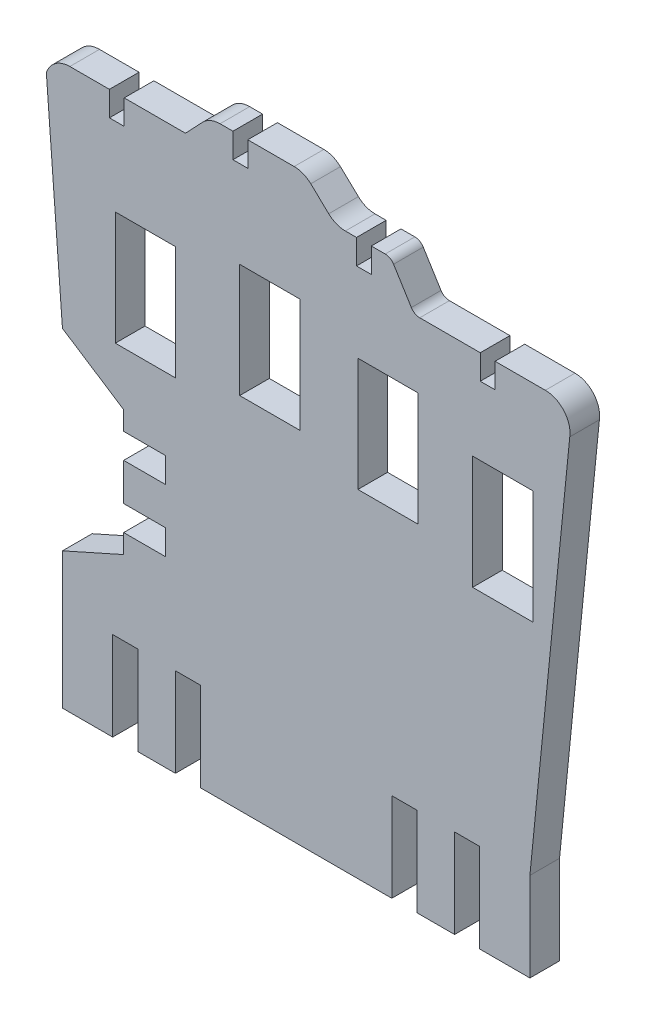
from build123d import *

# Parameters (mm, degrees)
SKETCH1_W           = 12.2
SKETCH1_H           = 23
BOSS_EXTRUDE1_DEPTH = 6


with BuildPart() as part:
    # Sketch1 → Boss-Extrude1 (new body)
    with BuildSketch(Plane.XY):
        with BuildLine():
            Line((21.077436259, 96.487236066), (24.514288944, 100.118770675))
            ThreePointArc((24.514288944, 100.118770675), (26.133905044, 101.250028723), (28.068821983, 101.648773655))
            Line((28.068821983, 101.648773655), (30.683177697, 101.648773655))
            Line((30.683177697, 101.648773655), (30.683177697, 96.648773655))
            Line((30.683177697, 96.648773655), (33.683177697, 96.648773655))
            Line((33.683177697, 96.648773655), (33.683177697, 101.648773655))
            Line((33.683177697, 101.648773655), (43.068821983, 101.648773655))
            ThreePointArc((43.068821983, 101.648773655), (44.879241743, 101.301597143), (46.432801053, 100.309324643))
            Line((46.432801053, 100.309324643), (50.064335662, 96.872471958))
            ThreePointArc((50.064335662, 96.872471958), (51.617894972, 95.880199458), (53.428314733, 95.533022946))
            Line((53.428314733, 95.533022946), (55.683177697, 95.533022946))
            Line((55.683177697, 95.533022946), (55.683177697, 90.533022946))
            Line((55.683177697, 90.533022946), (58.683177697, 90.533022946))
            Line((58.683177697, 90.533022946), (58.683177697, 95.533022946))
            Line((58.683177697, 95.533022946), (61.489325132, 95.533022946))
            ThreePointArc((61.489325132, 95.533022946), (62.461477954, 95.280855573), (63.188485552, 94.587941837))
            Line((63.188485552, 94.587941837), (66.784051646, 88.796554795))
            ThreePointArc((66.784051646, 88.796554795), (67.511059245, 88.10364106), (68.483212066, 87.851473686))
            Line((68.483212066, 87.851473686), (80.727367549, 87.851473686))
            Line((80.727367549, 87.851473686), (80.727367549, 82.851473686))
            Line((80.727367549, 82.851473686), (83.727367549, 82.851473686))
            Line((83.727367549, 82.851473686), (83.727367549, 87.851473686))
            Line((83.727367549, 87.851473686), (93.887367549, 87.851473686))
            ThreePointArc((93.887367549, 87.851473686), (97.660193959, 86.132598628), (98.839013483, 82.157786039))
            Line((98.839013483, 82.157786039), (90.771737035, 1.27912723))
            Line((90.771737035, 1.27912723), (90.771737035, -16.699114739))
            Line((90.771737035, -16.699114739), (80.611737035, -16.699114739))
            Line((80.611737035, -16.699114739), (80.611737035, 1.27912723))
            Line((80.611737035, 1.27912723), (75.531737035, 1.27912723))
            Line((75.531737035, 1.27912723), (75.531737035, -16.699114739))
            Line((75.531737035, -16.699114739), (67.911737035, -16.699114739))
            Line((67.911737035, -16.699114739), (67.911737035, 1.27912723))
            Line((67.911737035, 1.27912723), (62.831737035, 1.27912723))
            Line((62.831737035, 1.27912723), (62.831737035, -16.699114739))
            Line((62.831737035, -16.699114739), (24.124020717, -16.699114739))
            Line((24.124020717, -16.699114739), (24.124020717, 1.27912723))
            Line((24.124020717, 1.27912723), (19.044020717, 1.27912723))
            Line((19.044020717, 1.27912723), (19.044020717, -16.699114739))
            Line((19.044020717, -16.699114739), (11.424020717, -16.699114739))
            Line((11.424020717, -16.699114739), (11.424020717, 1.27912723))
            Line((11.424020717, 1.27912723), (6.344020717, 1.27912723))
            Line((6.344020717, 1.27912723), (6.344020717, -16.699114739))
            Line((6.344020717, -16.699114739), (-3.815979283, -16.699114739))
            Line((-3.815979283, -16.699114739), (-3.815979283, 1.27912723))
            Line((-3.815979283, 1.27912723), (-3.815979283, 10.864597722))
            Line((-3.815979283, 10.864597722), (8.569519397, 16.399351506))
            Line((8.569519397, 16.399351506), (8.569519397, 20.261157087))
            Line((8.569519397, 20.261157087), (17.062273891, 20.261157087))
            Line((17.062273891, 20.261157087), (17.062273891, 25.341157087))
            Line((17.062273891, 25.341157087), (8.569519397, 25.341157087))
            Line((8.569519397, 25.341157087), (8.569519397, 32.909351506))
            Line((8.569519397, 32.909351506), (17.062273891, 32.909351506))
            Line((17.062273891, 32.909351506), (17.062273891, 37.989351506))
            Line((17.062273891, 37.989351506), (8.569519397, 37.989351506))
            Line((8.569519397, 37.989351506), (8.569519397, 41.799351506))
            Line((8.569519397, 41.799351506), (-3.815979283, 49.840454802))
            Line((-3.815979283, 49.840454802), (-7.075944103, 93.020454802))
            ThreePointArc((-7.075944103, 93.020454802), (-5.26079125, 95.528652506), (-2.316822303, 96.487236066))
            Line((-2.316822303, 96.487236066), (5.683177697, 96.487236066))
            Line((5.683177697, 96.487236066), (5.683177697, 91.487236066))
            Line((5.683177697, 91.487236066), (8.683177697, 91.487236066))
            Line((8.683177697, 91.487236066), (8.683177697, 96.487236066))
            Line((8.683177697, 96.487236066), (21.077436259, 96.487236066))
        make_face()
        with Locations((85.276683747, 57.465671264)):
            Rectangle(SKETCH1_W, SKETCH1_H, mode=Mode.SUBTRACT)
        with Locations((62.066293543, 63.009787098)):
            Rectangle(SKETCH1_W, SKETCH1_H, mode=Mode.SUBTRACT)
        with Locations((38.142588603, 67.50121976)):
            Rectangle(SKETCH1_W, SKETCH1_H, mode=Mode.SUBTRACT)
        with Locations((12.98270306, 64.099542403)):
            Rectangle(SKETCH1_W, SKETCH1_H, mode=Mode.SUBTRACT)
    extrude(amount=BOSS_EXTRUDE1_DEPTH)


solid = part.part
